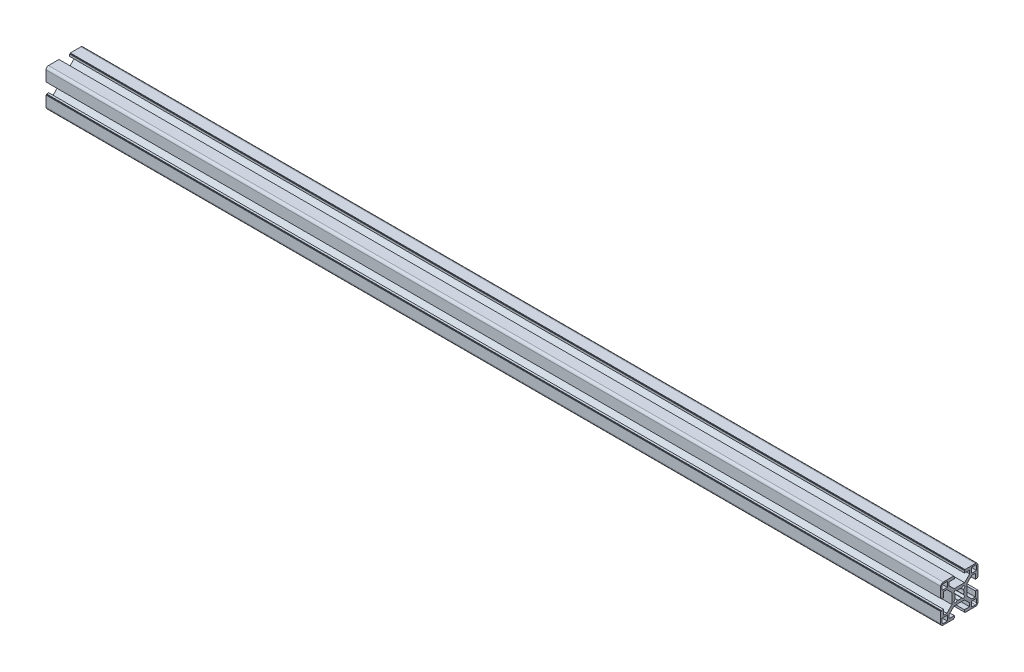
from build123d import *

# Parameters (mm, degrees)
BR_EXTRUDE_DEPTH      = 360
BR_EXTRUDE_DEPTH_BACK = 360


with BuildPart() as part:
    # Sketch2 → BR_Extrude (new body, two sides)
    with BuildSketch(Plane(origin=(0, 0, 0), x_dir=(0, 0, -1), z_dir=(1, 0, 0))) as br_extrude_sk:
        with BuildLine():
            Line((-6, 4.196877708), (-10.053122292, 8.25))
            Line((-10.053122292, 8.25), (-12.8, 8.25))
            Line((-12.8, 8.25), (-12.800036742, 4.05))
            Line((-12.800036742, 4.05), (-14.5, 4.05))
            Line((-14.5, 4.05), (-14.5, 4.55))
            Line((-14.5, 4.55), (-15, 4.55))
            Line((-15, 4.55), (-15, 13))
            ThreePointArc((-15, 13), (-14.414213562, 14.414213562), (-13, 15))
            Line((-13, 15), (-4.55, 15))
            Line((-4.55, 15), (-4.55, 14.5))
            Line((-4.55, 14.5), (-4.05, 14.5))
            Line((-4.05, 14.5), (-4.05, 12.800036742))
            Line((-4.05, 12.800036742), (-8.25, 12.8))
            Line((-8.25, 12.8), (-8.25, 10.053122292))
            Line((-8.25, 10.053122292), (-4.196877708, 6))
            Line((-4.196877708, 6), (4.196877708, 6))
            Line((4.196877708, 6), (8.25, 10.053122292))
            Line((8.25, 10.053122292), (8.25, 12.8))
            Line((8.25, 12.8), (4.05, 12.800036742))
            Line((4.05, 12.800036742), (4.05, 14.5))
            Line((4.05, 14.5), (4.55, 14.5))
            Line((4.55, 14.5), (4.55, 15))
            Line((4.55, 15), (13, 15))
            ThreePointArc((13, 15), (14.414213562, 14.414213562), (15, 13))
            Line((15, 13), (15, 4.55))
            Line((15, 4.55), (14.5, 4.55))
            Line((14.5, 4.55), (14.5, 4.05))
            Line((14.5, 4.05), (12.800036742, 4.05))
            Line((12.800036742, 4.05), (12.8, 8.25))
            Line((12.8, 8.25), (10.053122292, 8.25))
            Line((10.053122292, 8.25), (6, 4.196877708))
            Line((6, 4.196877708), (6, -4.196877708))
            Line((6, -4.196877708), (10.053122292, -8.25))
            Line((10.053122292, -8.25), (12.8, -8.25))
            Line((12.8, -8.25), (12.800036742, -4.05))
            Line((12.800036742, -4.05), (14.5, -4.05))
            Line((14.5, -4.05), (14.5, -4.55))
            Line((14.5, -4.55), (15, -4.55))
            Line((15, -4.55), (15, -13))
            ThreePointArc((15, -13), (14.414213562, -14.414213562), (13, -15))
            Line((13, -15), (4.55, -15))
            Line((4.55, -15), (4.55, -14.5))
            Line((4.55, -14.5), (4.05, -14.5))
            Line((4.05, -14.5), (4.05, -12.800036742))
            Line((4.05, -12.800036742), (8.25, -12.8))
            Line((8.25, -12.8), (8.25, -10.053122292))
            Line((8.25, -10.053122292), (4.196877708, -6))
            Line((4.196877708, -6), (-4.196877708, -6))
            Line((-4.196877708, -6), (-8.25, -10.053122292))
            Line((-8.25, -10.053122292), (-8.25, -12.8))
            Line((-8.25, -12.8), (-4.05, -12.800036742))
            Line((-4.05, -12.800036742), (-4.05, -14.5))
            Line((-4.05, -14.5), (-4.55, -14.5))
            Line((-4.55, -14.5), (-4.55, -15))
            Line((-4.55, -15), (-13, -15))
            ThreePointArc((-13, -15), (-14.414213562, -14.414213562), (-15, -13))
            Line((-15, -13), (-15, -4.55))
            Line((-15, -4.55), (-14.5, -4.55))
            Line((-14.5, -4.55), (-14.5, -4.05))
            Line((-14.5, -4.05), (-12.800036742, -4.05))
            Line((-12.800036742, -4.05), (-12.8, -8.25))
            Line((-12.8, -8.25), (-10.053122292, -8.25))
            Line((-10.053122292, -8.25), (-6, -4.196877708))
            Line((-6, -4.196877708), (-6, 4.196877708))
        make_face()
        with BuildLine():
            Line((-13.85, -9.7), (-13.85, -12.85))
            ThreePointArc((-13.85, -12.85), (-13.557106781, -13.557106781), (-12.85, -13.85))
            Line((-12.85, -13.85), (-9.7, -13.85))
            Line((-9.7, -13.85), (-9.7, -9.7))
            Line((-9.7, -9.7), (-13.85, -9.7))
        make_face(mode=Mode.SUBTRACT)
        with BuildLine():
            Line((9.7, -13.85), (12.85, -13.85))
            ThreePointArc((12.85, -13.85), (13.557106781, -13.557106781), (13.85, -12.85))
            Line((13.85, -12.85), (13.85, -9.7))
            Line((13.85, -9.7), (9.7, -9.7))
            Line((9.7, -9.7), (9.7, -13.85))
        make_face(mode=Mode.SUBTRACT)
        with BuildLine():
            Line((13.85, 9.7), (13.85, 12.85))
            ThreePointArc((13.85, 12.85), (13.557106781, 13.557106781), (12.85, 13.85))
            Line((12.85, 13.85), (9.7, 13.85))
            Line((9.7, 13.85), (9.7, 9.7))
            Line((9.7, 9.7), (13.85, 9.7))
        make_face(mode=Mode.SUBTRACT)
        with BuildLine():
            Line((-9.7, 13.85), (-12.85, 13.85))
            ThreePointArc((-12.85, 13.85), (-13.557106781, 13.557106781), (-13.85, 12.85))
            Line((-13.85, 12.85), (-13.85, 9.7))
            Line((-13.85, 9.7), (-9.7, 9.7))
            Line((-9.7, 9.7), (-9.7, 13.85))
        make_face(mode=Mode.SUBTRACT)
        with BuildLine():
            Line((-3.272394192, -1.616767223), (-4.59052283, -3.187651763))
            Line((-4.59052283, -3.187651763), (-3.187651763, -4.59052283))
            Line((-3.187651763, -4.59052283), (-1.616767223, -3.272394192))
            ThreePointArc((-1.616767223, -3.272394192), (0, -3.65), (1.616767223, -3.272394192))
            Line((1.616767223, -3.272394192), (3.187651763, -4.59052283))
            Line((3.187651763, -4.59052283), (4.59052283, -3.187651763))
            Line((4.59052283, -3.187651763), (3.272394192, -1.616767223))
            ThreePointArc((3.272394192, -1.616767223), (3.65, 0), (3.272394192, 1.616767223))
            Line((3.272394192, 1.616767223), (4.59052283, 3.187651763))
            Line((4.59052283, 3.187651763), (3.187651763, 4.59052283))
            Line((3.187651763, 4.59052283), (1.616767223, 3.272394192))
            ThreePointArc((1.616767223, 3.272394192), (0, 3.65), (-1.616767223, 3.272394192))
            Line((-1.616767223, 3.272394192), (-3.187651763, 4.59052283))
            Line((-3.187651763, 4.59052283), (-4.59052283, 3.187651763))
            Line((-4.59052283, 3.187651763), (-3.272394192, 1.616767223))
            ThreePointArc((-3.272394192, 1.616767223), (-3.65, 0), (-3.272394192, -1.616767223))
        make_face(mode=Mode.SUBTRACT)
    extrude(amount=BR_EXTRUDE_DEPTH)
    extrude(br_extrude_sk.sketch, amount=-BR_EXTRUDE_DEPTH_BACK)


solid = part.part
